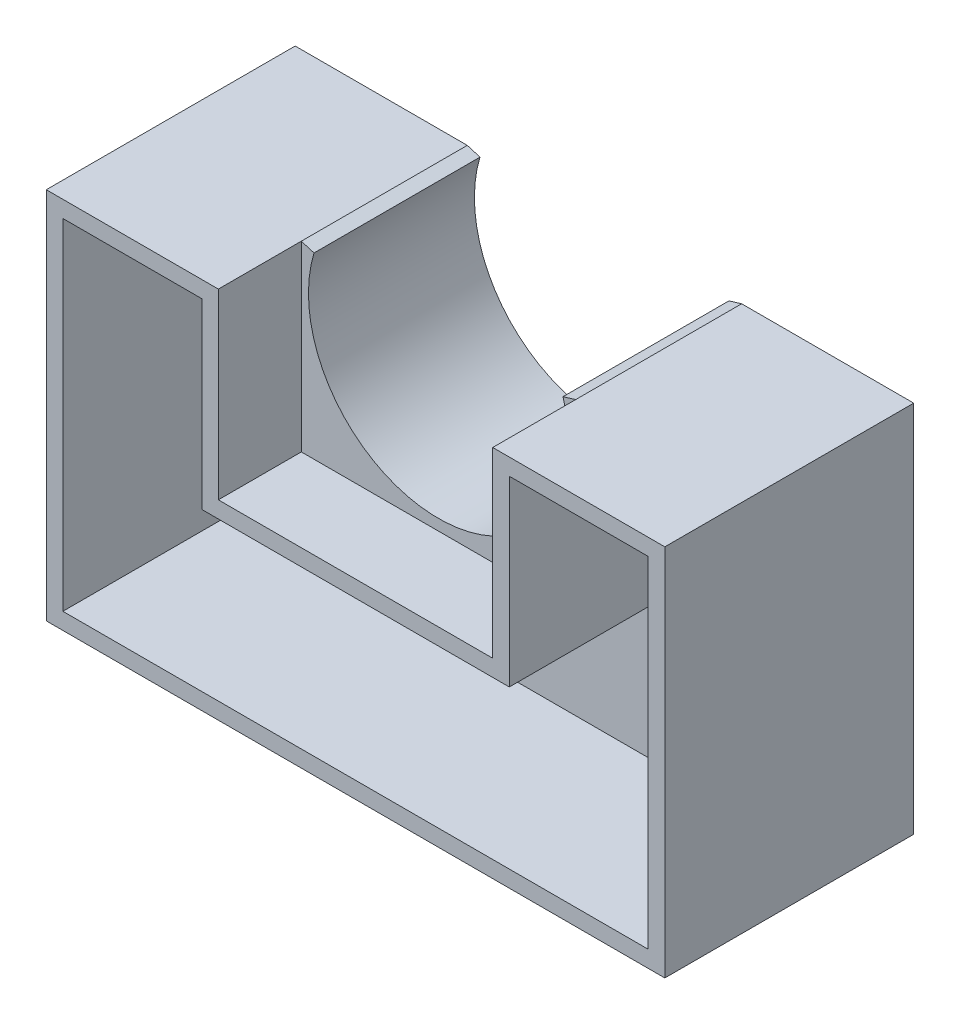
from build123d import *

# Parameters (mm, degrees)
BOSS_EXTRUDE1_DEPTH = 12.7
SKETCH2_W           = 12.7
SKETCH2_H           = 12.7
BOSS_EXTRUDE2_DEPTH = 22.22735
BOSS_EXTRUDE3_DEPTH = 12.7
SKETCH4_W           = 12.7
SKETCH4_H           = 12.7
BOSS_EXTRUDE4_DEPTH = 22.22735
BOSS_EXTRUDE5_DEPTH = 12.7
BOSS_EXTRUDE6_DEPTH = 6.35
CUT_EXTRUDE1_DEPTH  = 12.7
SKETCH9_W           = 10.16
SKETCH9_H           = 5.08
SKETCH9_W_2         = 5.08
SKETCH9_H_2         = 10.16
CUT_EXTRUDE2_DEPTH  = 2


with BuildPart() as part:
    # Sketch1 → Boss-Extrude1 (new body)
    with BuildSketch(Plane.XY):
        with BuildLine():
            Line((10.499121608, 3.177349953), (9.526676859, 2.883058926))
            ThreePointArc((9.526676859, 2.883058926), (0, -9.953371325), (-9.526676859, 2.883058926))
            Line((-9.526676859, 2.883058926), (-10.499121608, 3.177349953))
            ThreePointArc((-10.499121608, 3.177349953), (-10.851172075, 1.605980037), (-10.969371325, 0))
            Line((-10.969371325, 0), (-10.969371325, -19.05))
            Line((-10.969371325, -19.05), (-23.669371325, -19.05))
            Line((-23.669371325, -19.05), (-23.669371325, -25.4))
            Line((-23.669371325, -25.4), (23.669371325, -25.4))
            Line((23.669371325, -25.4), (23.669371325, -19.05))
            Line((23.669371325, -19.05), (10.969371325, -19.05))
            Line((10.969371325, -19.05), (10.969371325, 0))
            ThreePointArc((10.969371325, 0), (10.851172075, 1.605980037), (10.499121608, 3.177349953))
        make_face()
    extrude(amount=BOSS_EXTRUDE1_DEPTH)

    # Sketch2 → Boss-Extrude2 (add)
    with BuildSketch(Plane(origin=(0, -19.05, 0), x_dir=(1, 0, 0), z_dir=(0, 1, 0))):
        with Locations((17.319371325, -6.35)):
            Rectangle(SKETCH2_W, SKETCH2_H)
    extrude(amount=BOSS_EXTRUDE2_DEPTH)

    # Sketch3 → Boss-Extrude3 (add, through all)
    with BuildSketch(Plane(origin=(0, 0, 0), x_dir=(-1, 0, 0), z_dir=(0, 0, -1))):
        with BuildLine():
            Line((-10.969371325, 0), (-10.969371325, 3.177349953))
            Line((-10.969371325, 3.177349953), (-10.499121608, 3.177349953))
            ThreePointArc((-10.499121608, 3.177349953), (-10.851172075, 1.605980037), (-10.969371325, 0))
        make_face()
    extrude(amount=-BOSS_EXTRUDE3_DEPTH)

    # Sketch4 → Boss-Extrude4 (add)
    with BuildSketch(Plane(origin=(0, -19.05, 0), x_dir=(1, 0, 0), z_dir=(0, 1, 0))):
        with Locations((-17.319371325, -6.35)):
            Rectangle(SKETCH4_W, SKETCH4_H)
    extrude(amount=BOSS_EXTRUDE4_DEPTH)

    # Sketch5 → Boss-Extrude5 (add, through all)
    with BuildSketch(Plane(origin=(0, 0, 0), x_dir=(-1, 0, 0), z_dir=(0, 0, -1))):
        with BuildLine():
            Line((10.969371325, 3.177349953), (10.969371325, 0))
            ThreePointArc((10.969371325, 0), (10.851172075, 1.605980037), (10.499121608, 3.177349953))
            Line((10.499121608, 3.177349953), (10.969371325, 3.177349953))
        make_face()
    extrude(amount=-BOSS_EXTRUDE5_DEPTH)

    # Sketch6 → Boss-Extrude6 (add)
    with BuildSketch(Plane.XY.offset(12.7)):
        Polygon((-23.669371325, 3.177349953), (-23.669371325, -25.4), (23.669371325, -25.4), (23.669371325, 3.177349953), (10.499121608, 3.177349953), (10.499121608, -10.792650047), (-10.499121608, -10.792650047), (-10.499121608, 3.177349953), align=None)
    extrude(amount=BOSS_EXTRUDE6_DEPTH)

    # Sketch7 → Cut-Extrude1 (cut)
    with BuildSketch(Plane.XY.offset(19.05)):
        Polygon((-11.769121608, 1.907349953), (-22.399371325, 1.907349953), (-22.399371325, -24.13), (22.399371325, -24.13), (22.399371325, 1.907349953), (11.769121608, 1.907349953), (11.769121608, -12.062650047), (-11.769121608, -12.062650047), align=None)
    extrude(amount=-CUT_EXTRUDE1_DEPTH, mode=Mode.SUBTRACT)

    # Sketch9 → Cut-Extrude2 (cut)
    with BuildSketch(Plane(origin=(0, 0, 0), x_dir=(-1, 0, 0), z_dir=(0, 0, -1))):
        with Locations((-17.78, 0)):
            Rectangle(SKETCH9_W, SKETCH9_H)
        with Locations((0, -17.78)):
            Rectangle(SKETCH9_W_2, SKETCH9_H_2)
    extrude(amount=-CUT_EXTRUDE2_DEPTH, mode=Mode.SUBTRACT)


solid = part.part
